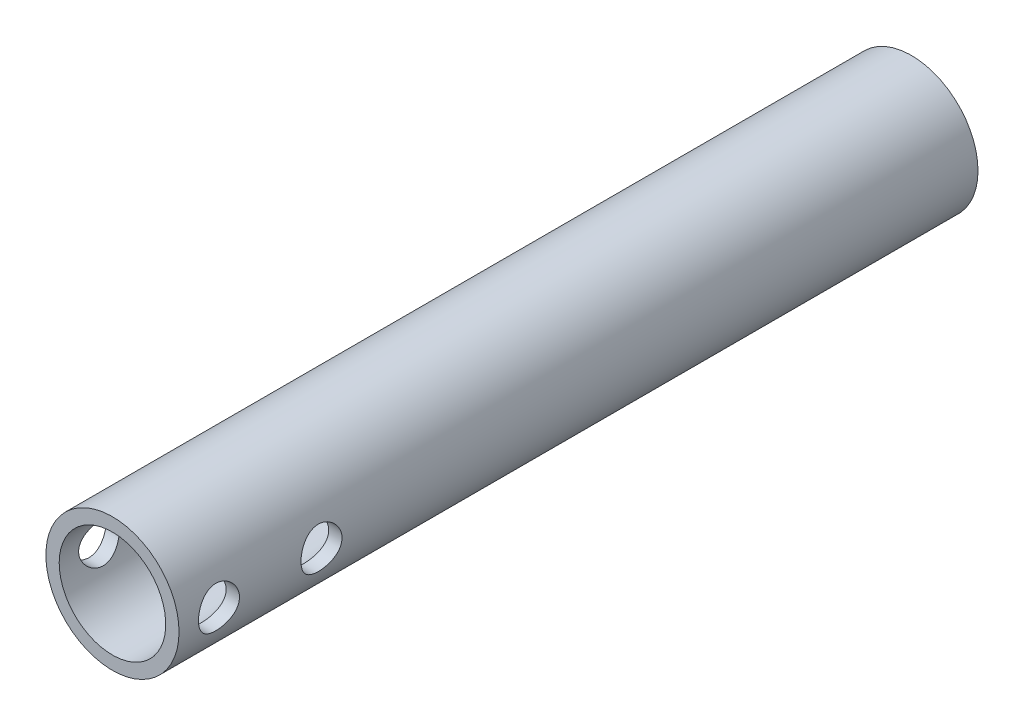
from build123d import *

# Parameters (mm, degrees)
SKETCH2_R               = 6.35
BOSS_EXTRUDE1_DEPTH     = 355.6
SKETCH3_R               = 1.9558
CUT_EXTRUDE5_DEPTH      = 177.8
SKETCH4_W               = 279.4
SKETCH4_H               = 48.019067171
CUT_EXTRUDE7_DEPTH      = 7.3500001
CUT_EXTRUDE7_DEPTH_BACK = 7.3500001
SKETCH5_R               = 5.08
CUT_EXTRUDE8_DEPTH      = 77.2000001


with BuildPart() as part:
    # Sketch2 → Boss-Extrude1 (new body)
    with BuildSketch(Plane.XY):
        Circle(SKETCH2_R)
    extrude(amount=BOSS_EXTRUDE1_DEPTH)

    # Sketch3 → Cut-Extrude5 (cut, symmetric)
    with BuildSketch(Plane(origin=(0, 0, 0), x_dir=(0, 0, -1), z_dir=(1, 0, 0))):
        with Locations((-351.79, 0)):
            Circle(SKETCH3_R)
        with Locations((-342.011, 0)):
            Circle(SKETCH3_R)
        with Locations((-13.589, 0)):
            Circle(SKETCH3_R)
        with Locations((-3.81, 0)):
            Circle(SKETCH3_R)
    extrude(amount=CUT_EXTRUDE5_DEPTH, both=True, mode=Mode.SUBTRACT)

    # Sketch4 → Cut-Extrude7 (cut, two sides)
    with BuildSketch(Plane(origin=(0, 0, 0), x_dir=(0, 0, -1), z_dir=(1, 0, 0))) as cut_extrude7_sk:
        with Locations((-139.7, 0.553941087)):
            Rectangle(SKETCH4_W, SKETCH4_H)
    extrude(amount=CUT_EXTRUDE7_DEPTH, mode=Mode.SUBTRACT)
    extrude(cut_extrude7_sk.sketch, amount=-CUT_EXTRUDE7_DEPTH_BACK, mode=Mode.SUBTRACT)

    # Sketch5 → Cut-Extrude8 (cut, through all)
    with BuildSketch(Plane(origin=(0, 0, 279.4), x_dir=(-1, 0, 0), z_dir=(0, 0, -1))):
        Circle(SKETCH5_R)
    extrude(amount=-CUT_EXTRUDE8_DEPTH, mode=Mode.SUBTRACT)


solid = part.part
